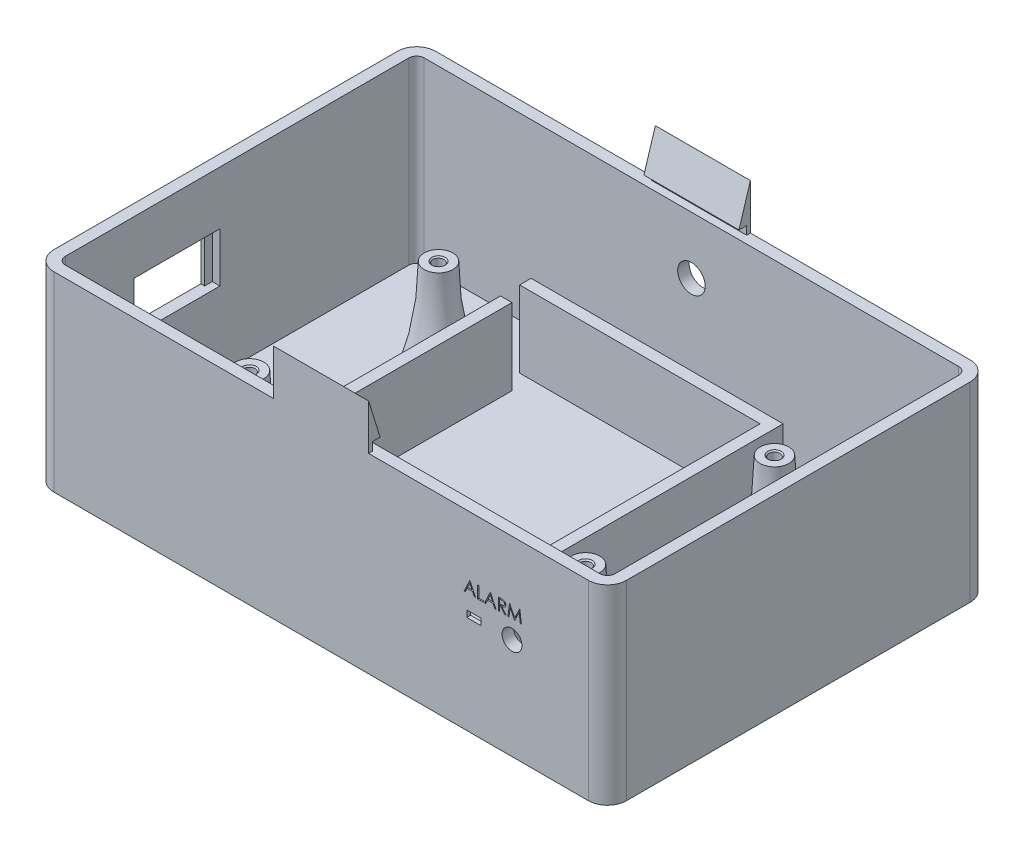
from build123d import *

# Parameters (mm, degrees)
SKETCH1_W                         = 150
SKETCH1_H                         = 100
BOSS_EXTRUDE1_DEPTH               = 50
FILLET1_R                         = 5
SHELL1_T                          = -3
SKETCH2_W                         = 66
SKETCH2_H                         = 76
SKETCH2_W_2                       = 60
SKETCH2_H_2                       = 70
BOSS_EXTRUDE2_DEPTH               = 20
SKETCH3_W                         = 5
SKETCH3_H                         = 20
CUT_EXTRUDE1_DEPTH                = 3
SKETCH4_R                         = 2.75
BOSS_EXTRUDE3_DEPTH               = 25
M3_5X0_6_TAPPED_HOLE1_D           = 2.9
M3_5X0_6_TAPPED_HOLE1_DEPTH       = 25
M3_5X0_6_TAPPED_HOLE1_CSINK_D     = 3.55
M3_5X0_6_TAPPED_HOLE1_CSINK_ANGLE = 90
M3_5X0_6_TAPPED_HOLE1_TIP         = 0.871247898
LPATTERN1_COUNT                   = 2
LPATTERN1_PITCH                   = 88
LPATTERN1_COUNT_DIR2              = 2
LPATTERN1_PITCH_DIR2              = 49.5
SKETCH9_W                         = 2
SKETCH9_H                         = 24
CUT_EXTRUDE2_DEPTH                = 4
SKETCH10_W                        = 18.5
SKETCH10_H                        = 13
CUT_EXTRUDE3_DEPTH                = 4
SKETCH11_W                        = 2
SKETCH11_H                        = 13
CUT_EXTRUDE4_DEPTH                = 2
SKETCH12_R                        = 3.6
CUT_EXTRUDE5_DEPTH                = 4
SKETCH13_R                        = 2.6
SKETCH13_W                        = 3.7
SKETCH13_H                        = 1.7
CUT_EXTRUDE6_DEPTH                = 4
SKETCH14_W                        = 10.2
SKETCH14_H                        = 4.2
CUT_EXTRUDE7_DEPTH                = 2
CUT_EXTRUDE8_DEPTH                = 1
SKETCH16_W                        = 24.9
SKETCH16_H                        = 11.9
BOSS_EXTRUDE4_DEPTH               = 3
SKETCH18_W                        = 2
SKETCH18_H                        = 2.2
CUT_EXTRUDE10_DEPTH               = 88.45
SKETCH19_W                        = 24.9
SKETCH19_H                        = 11.9
BOSS_EXTRUDE5_DEPTH               = 3
SKETCH20_W                        = 2
SKETCH20_H                        = 2.2
CUT_EXTRUDE11_DEPTH               = 88.45


with BuildPart() as part:
    # Sketch1 → Boss-Extrude1 (new body)
    with BuildSketch(Plane(origin=(0, 0, 0), x_dir=(1, 0, 0), z_dir=(0, 1, 0))):
        Rectangle(SKETCH1_W, SKETCH1_H)
    extrude(amount=BOSS_EXTRUDE1_DEPTH)

    # Fillet1
    fillet1_edges = [part.edges().sort_by_distance(p)[0] for p in [
        (75, 25, 50),
        (-75, 25, 50),
        (-75, 25, -50),
        (75, 25, -50),
    ]]
    fillet(fillet1_edges, radius=FILLET1_R)

    # Shell1
    shell1_openings = [part.faces().sort_by_distance(p)[0] for p in [
        (0, 50, 0),
    ]]
    offset(amount=SHELL1_T, openings=shell1_openings, kind=Kind.INTERSECTION)

    # Sketch2 → Boss-Extrude2 (add)
    with BuildSketch(Plane(origin=(0, 3, 0), x_dir=(1, 0, 0), z_dir=(0, 1, 0))):
        Rectangle(SKETCH2_W, SKETCH2_H)
        Rectangle(SKETCH2_W_2, SKETCH2_H_2, mode=Mode.SUBTRACT)
    extrude(amount=BOSS_EXTRUDE2_DEPTH)

    # Sketch3 → Cut-Extrude1 (cut)
    with BuildSketch(Plane(origin=(-30, 0, 0), x_dir=(0, 0, -1), z_dir=(1, 0, 0))):
        with Locations((32.5, 13)):
            Rectangle(SKETCH3_W, SKETCH3_H)
    extrude(amount=-CUT_EXTRUDE1_DEPTH, mode=Mode.SUBTRACT)

    # Sketch4 → Boss-Extrude3 (add)
    with BuildSketch(Plane(origin=(0, 3, 0), x_dir=(1, 0, 0), z_dir=(0, 1, 0))):
        with Locations((-44, 24.75)):
            Circle(SKETCH4_R)
        with Locations((-44, -24.75)):
            Circle(SKETCH4_R)
        with Locations((44, 24.75)):
            Circle(SKETCH4_R)
        with Locations((44, -24.75)):
            Circle(SKETCH4_R)
    extrude(amount=BOSS_EXTRUDE3_DEPTH)

    # M3.5x0.6 Tapped Hole1
    with Locations(Plane(origin=(0, 28, 0), x_dir=(1, 0, 0), z_dir=(0, 1, 0))):
        with Locations((-44, 24.75), (44, 24.75), (44, -24.75), (-44, -24.75)):
            CounterSinkHole(M3_5X0_6_TAPPED_HOLE1_D / 2, M3_5X0_6_TAPPED_HOLE1_CSINK_D / 2, depth=M3_5X0_6_TAPPED_HOLE1_DEPTH, counter_sink_angle=M3_5X0_6_TAPPED_HOLE1_CSINK_ANGLE)
            with Locations((0, 0, -(M3_5X0_6_TAPPED_HOLE1_DEPTH + M3_5X0_6_TAPPED_HOLE1_TIP / 2))):  # 118° drill point
                Cone(0, M3_5X0_6_TAPPED_HOLE1_D / 2, M3_5X0_6_TAPPED_HOLE1_TIP, mode=Mode.SUBTRACT)

    # Sketch8 → Revolve1 (revolve)
    with BuildSketch(Plane.XY.offset(-24.75)):
        with BuildLine():
            Line((-41.25, 3), (-41.25, 28))
            Line((-41.25, 28), (-40.25, 28))
            ThreePointArc((-40.25, 28), (-39.243680632, 15.341011099), (-36.25, 3))
            Line((-36.25, 3), (-41.25, 3))
        make_face()
    revolve1 = revolve(axis=Axis((-44, 3, -24.75), (0, 1, 0)))

    # LPattern1: Revolve1 2 × 2
    with Locations(*[(i * LPATTERN1_PITCH, 0, j * LPATTERN1_PITCH_DIR2) for i in range(LPATTERN1_COUNT) for j in range(LPATTERN1_COUNT_DIR2) if (i, j) != (0, 0)]):
        add(revolve1)

    # Sketch9 → Cut-Extrude2 (cut, through all)
    with BuildSketch(Plane(origin=(0, 3, 0), x_dir=(1, 0, 0), z_dir=(0, 1, 0))):
        with Locations((67, 0)):
            Rectangle(SKETCH9_W, SKETCH9_H)
    extrude(amount=-CUT_EXTRUDE2_DEPTH, mode=Mode.SUBTRACT)

    # Sketch10 → Cut-Extrude3 (cut, through all)
    with BuildSketch(Plane(origin=(-72, 0, 0), x_dir=(0, 0, -1), z_dir=(1, 0, 0))):
        with Locations((-15.75, 29.5)):
            Rectangle(SKETCH10_W, SKETCH10_H)
    extrude(amount=-CUT_EXTRUDE3_DEPTH, mode=Mode.SUBTRACT)

    # Sketch11 → Cut-Extrude4 (cut)
    with BuildSketch(Plane(origin=(-72, 0, 0), x_dir=(0, 0, -1), z_dir=(1, 0, 0))):
        with Locations((-5.5, 29.5)):
            Rectangle(SKETCH11_W, SKETCH11_H)
        with Locations((-26, 29.5)):
            Rectangle(SKETCH11_W, SKETCH11_H)
    extrude(amount=-CUT_EXTRUDE4_DEPTH, mode=Mode.SUBTRACT)

    # Sketch12 → Cut-Extrude5 (cut, through all)
    with BuildSketch(Plane.XY.offset(-47)):
        with Locations((0, 35)):
            Circle(SKETCH12_R)
    extrude(amount=-CUT_EXTRUDE5_DEPTH, mode=Mode.SUBTRACT)

    # Sketch13 → Cut-Extrude6 (cut, through all)
    with BuildSketch(Plane(origin=(0, 0, 47), x_dir=(-1, 0, 0), z_dir=(0, 0, -1))):
        with Locations((-50, 26.5)):
            Circle(SKETCH13_R)
        with Locations((-40, 26.5)):
            Rectangle(SKETCH13_W, SKETCH13_H)
    extrude(amount=-CUT_EXTRUDE6_DEPTH, mode=Mode.SUBTRACT)

    # Sketch14 → Cut-Extrude7 (cut)
    with BuildSketch(Plane(origin=(0, 0, 47), x_dir=(-1, 0, 0), z_dir=(0, 0, -1))):
        with Locations((-40, 26.5)):
            Rectangle(SKETCH14_W, SKETCH14_H)
    extrude(amount=-CUT_EXTRUDE7_DEPTH, mode=Mode.SUBTRACT)

    # Sketch15 → Cut-Extrude8 (cut)
    with BuildSketch(Plane.XY.offset(50)):
        Polygon((38.992799181, 34.457148185), (40.458183796, 31.282148185), (40.148443211, 31.282148185), (39.679062201, 32.299776391), (38.239754309, 32.299776391), (37.757016929, 31.282148185), (37.446004309, 31.282148185), (38.952094052, 34.457148185), align=None)
        Polygon((38.969266528, 33.838303033), (38.394306592, 32.625417416), (39.528962041, 32.625417416), align=None, mode=Mode.SUBTRACT)
        Polygon((41.028055591, 34.457148185), (41.312991488, 34.457148185), (41.312991488, 31.607789211), (42.534145334, 31.607789211), (42.534145334, 31.282148185), (41.028055591, 31.282148185), align=None)
        Polygon((44.365876104, 34.457148185), (45.831260719, 31.282148185), (45.521520134, 31.282148185), (45.052139124, 32.299776391), (43.612831232, 32.299776391), (43.130093852, 31.282148185), (42.819081232, 31.282148185), (44.325170975, 34.457148185), align=None)
        Polygon((44.342343451, 33.838303033), (43.767383515, 32.625417416), (44.902038964, 32.625417416), align=None, mode=Mode.SUBTRACT)
        with BuildLine():
            Line((46.401132514, 34.457148185), (47.036514124, 34.457148185))
            add(Edge.make_bspline(
                [(47.036514124, 34.457148185), (47.078915005, 34.457007047), (47.160329393, 34.456736045), (47.276963717, 34.45522496), (47.382942584, 34.450893937), (47.478210581, 34.447166865), (47.562765961, 34.440370604), (47.636868003, 34.433874874), (47.700175414, 34.425371625), (47.738498437, 34.417474562), (47.755850062, 34.413898987)],
                knots=[0, 0, 0, 0, 0.000127205, 0.000244248, 0.000349896, 0.000445402, 0.000530231, 0.00060434, 0.000668562, 0.000721699, 0.000721699, 0.000721699, 0.000721699], degree=3))
            add(Edge.make_bspline(
                [(47.755850062, 34.413898987), (47.779078928, 34.408159707), (47.825041126, 34.396803581), (47.891217257, 34.372800943), (47.954276679, 34.345024569), (48.013957449, 34.312400337), (48.069960631, 34.274686073), (48.12286367, 34.232532848), (48.172906626, 34.186171311), (48.218065676, 34.134432562), (48.260646102, 34.0801523), (48.296558641, 34.021456749), (48.327516234, 33.960078077), (48.352163774, 33.895392063), (48.372010221, 33.828026027), (48.386004024, 33.757369761), (48.394396173, 33.683745162), (48.395250571, 33.633527631), (48.395683796, 33.608064652)],
                knots=[0, 0, 0, 0, 7.1738e-05, 0.000141945, 0.000210849, 0.000278309, 0.000345694, 0.000413139, 0.000481086, 0.000550014, 0.000618962, 0.000687796, 0.000756061, 0.000824921, 0.000895163, 0.000966511, 0.001040751, 0.001117115, 0.001117115, 0.001117115, 0.001117115], degree=3))
            add(Edge.make_bspline(
                [(48.395683796, 33.608064652), (48.394351205, 33.56575995), (48.391750974, 33.483212519), (48.367507487, 33.363414434), (48.32779593, 33.251664127), (48.273074089, 33.148102305), (48.203387851, 33.054747648), (48.119636076, 32.972750592), (48.021772043, 32.904134386), (47.930668306, 32.856552199), (47.850191854, 32.826078632), (47.783940206, 32.804637078), (47.711670876, 32.788070866), (47.634076294, 32.77322989), (47.550833549, 32.762025138), (47.462142156, 32.753818585), (47.367938862, 32.748689555), (47.303224134, 32.747925736), (47.269932594, 32.747532801)],
                knots=[0, 0, 0, 0, 0.000126797, 0.000247415, 0.000364897, 0.000481551, 0.000597433, 0.000713022, 0.000831615, 0.000954788, 0.001020224, 0.001089619, 0.001163513, 0.001242474, 0.001326575, 0.001415367, 0.001509635, 0.001609508, 0.001609508, 0.001609508, 0.001609508], degree=3))
            Line((47.269932594, 32.747532801), (48.436388924, 31.282148185))
            Line((48.436388924, 31.282148185), (48.084035158, 31.282148185))
            Line((48.084035158, 31.282148185), (46.917578828, 32.747532801))
            Line((46.917578828, 32.747532801), (46.686068411, 32.747532801))
            Line((46.686068411, 32.747532801), (46.686068411, 31.282148185))
            Line((46.686068411, 31.282148185), (46.401132514, 31.282148185))
            Line((46.401132514, 31.282148185), (46.401132514, 34.457148185))
        make_face()
        with BuildLine():
            Line((46.686068411, 34.13150716), (46.686068411, 33.073173826))
            Line((46.686068411, 33.073173826), (47.267388523, 33.068721703))
            add(Edge.make_bspline(
                [(47.267388523, 33.068721703), (47.294530273, 33.068709695), (47.347138714, 33.068686421), (47.423248603, 33.072309347), (47.494114704, 33.076430786), (47.559465958, 33.082734835), (47.619331559, 33.090859271), (47.673681583, 33.101021979), (47.722604752, 33.112862064), (47.779662712, 33.131187824), (47.843377279, 33.160221855), (47.912620818, 33.202463415), (47.971587224, 33.255593973), (48.021405571, 33.316348465), (48.06143727, 33.383147062), (48.089660347, 33.455189054), (48.107569563, 33.530655718), (48.109681886, 33.58252443), (48.110747898, 33.608700669)],
                knots=[0, 0, 0, 0, 8.1413e-05, 0.000157801, 0.000228539, 0.000294357, 0.000354712, 0.000409723, 0.000460165, 0.000505621, 0.000589315, 0.00066961, 0.000747992, 0.000826171, 0.000904597, 0.000980539, 0.001057529, 0.001135968, 0.001135968, 0.001135968, 0.001135968], degree=3))
            add(Edge.make_bspline(
                [(48.110747898, 33.608700669), (48.109657403, 33.634233633), (48.107496439, 33.684830649), (48.089853627, 33.758904225), (48.06001826, 33.828814958), (48.019811658, 33.894278455), (47.970826711, 33.953701516), (47.913388409, 34.00454429), (47.849067268, 34.046499162), (47.788949823, 34.073309207), (47.735215931, 34.089746502), (47.688561882, 34.10131363), (47.63584647, 34.110606826), (47.576813733, 34.11805271), (47.511715682, 34.124452553), (47.440223163, 34.128763095), (47.362810512, 34.131315671), (47.309155796, 34.131441845), (47.281380911, 34.13150716)],
                knots=[0, 0, 0, 0, 7.6536e-05, 0.000151667, 0.000226914, 0.000303706, 0.000381394, 0.000457083, 0.00053294, 0.00061095, 0.000653596, 0.000701416, 0.000755061, 0.00081407, 0.000879888, 0.000951261, 0.001028897, 0.001112218, 0.001112218, 0.001112218, 0.001112218], degree=3))
            Line((47.281380911, 34.13150716), (46.686068411, 34.13150716))
        make_face(mode=Mode.SUBTRACT)
        Polygon((48.924850463, 31.282148185), (49.34398608, 34.457148185), (49.384691208, 34.457148185), (50.69552354, 31.85201998), (52.003175783, 34.457148185), (52.044516929, 34.457148185), (52.466196616, 31.282148185), (52.179988684, 31.282148185), (51.875972257, 33.566723506), (50.729868491, 31.282148185), (50.665630711, 31.282148185), (49.515074822, 33.571811647), (49.211694413, 31.282148185), align=None)
    extrude(amount=-CUT_EXTRUDE8_DEPTH, mode=Mode.SUBTRACT)

    # Sketch16 → Boss-Extrude4 (add)
    with BuildSketch(Plane.XY.offset(50)):
        with Locations((0, 55.95)):
            Rectangle(SKETCH16_W, SKETCH16_H)
    extrude(amount=-BOSS_EXTRUDE4_DEPTH)

    # Sketch18 → Cut-Extrude10 (cut, through all)
    with BuildSketch(Plane(origin=(12.45, 0, 0), x_dir=(0, 0, -1), z_dir=(1, 0, 0))):
        Polygon((-47, 61.9), (-50, 61.9), (-47, 52.2), align=None)
        with Locations((-48, 51.1)):
            Rectangle(SKETCH18_W, SKETCH18_H)
    extrude(amount=-CUT_EXTRUDE10_DEPTH, mode=Mode.SUBTRACT)

    # Sketch19 → Boss-Extrude5 (add)
    with BuildSketch(Plane(origin=(0, 0, -50), x_dir=(-1, 0, 0), z_dir=(0, 0, -1))):
        with Locations((0, 55.95)):
            Rectangle(SKETCH19_W, SKETCH19_H)
    extrude(amount=-BOSS_EXTRUDE5_DEPTH)

    # Sketch20 → Cut-Extrude11 (cut, through all)
    with BuildSketch(Plane.ZY.offset(12.45)):
        Polygon((-47, 61.9), (-50, 61.9), (-47, 52.2), align=None)
        with Locations((-48, 51.1)):
            Rectangle(SKETCH20_W, SKETCH20_H)
    extrude(amount=-CUT_EXTRUDE11_DEPTH, mode=Mode.SUBTRACT)


solid = part.part
